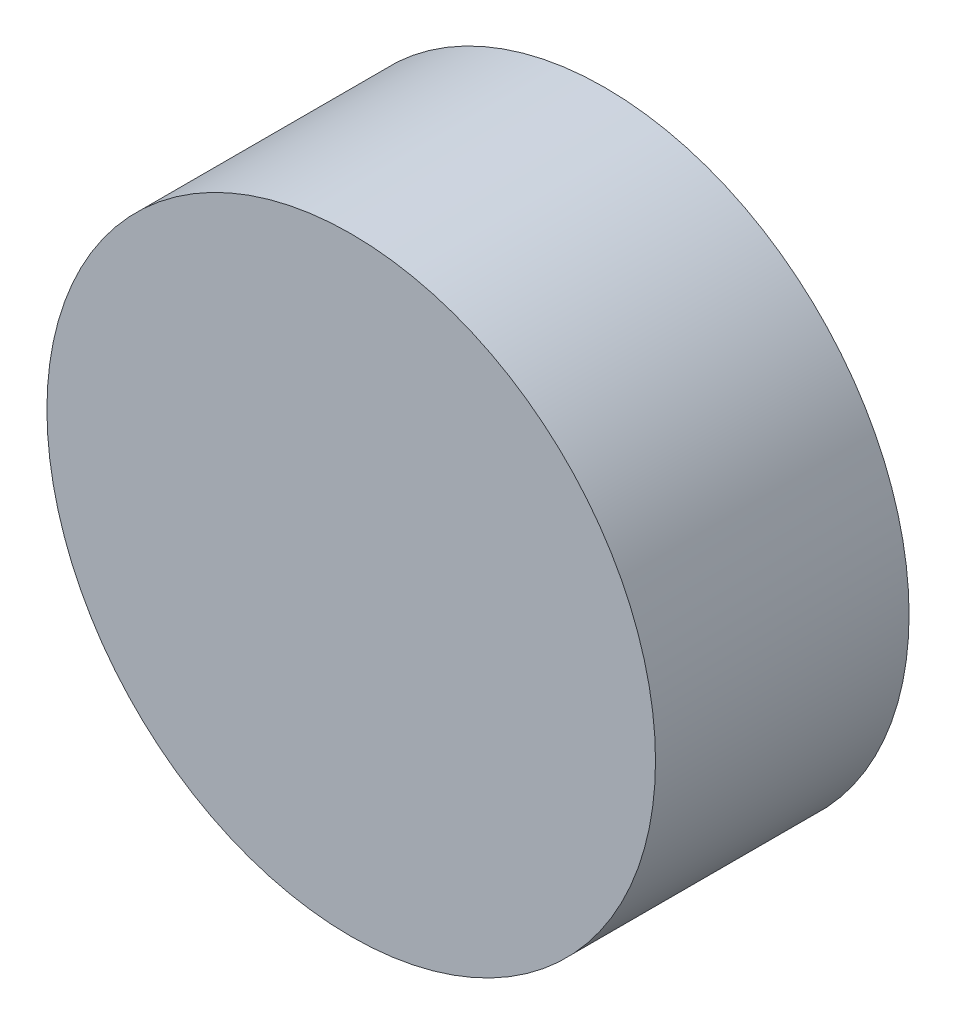
from build123d import *

# Parameters (mm, degrees)
SKETCH1_R           = 3
BOSS_EXTRUDE1_DEPTH = 2.5


with BuildPart() as part:
    # Sketch1 → Boss-Extrude1 (new body)
    with BuildSketch(Plane.XY):
        Circle(SKETCH1_R)
    extrude(amount=BOSS_EXTRUDE1_DEPTH)


solid = part.part
